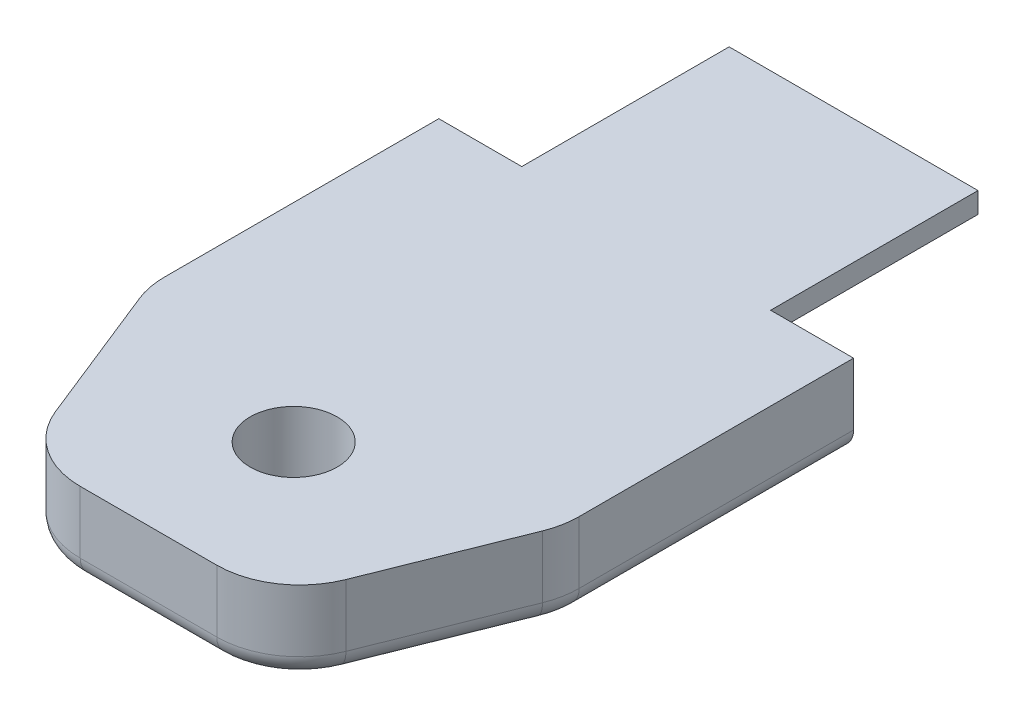
from build123d import *

# Parameters (mm, degrees)
BOSS_EXTRU_1_DEPTH      = 10
ESQUISSE2_W             = 20
ESQUISSE2_H             = 4
BOSS_EXTRU_2_DEPTH      = 24
ESQUISSE3_R             = 2.1
ENL_V_MAT_EXTRU_1_DEPTH = 5
CHANFREIN1_SIZE         = 10
CHANFREIN1_SIZE2        = 4
CHANFREIN1_PART_2_SIZE  = 10
CHANFREIN1_PART_2_SIZE2 = 4
CONG_1_R                = 4
CONG_2_R                = 1


with BuildPart() as part:
    # Esquisse1 → Boss.-Extru.1 (new body)
    with BuildSketch(Plane.XY):
        Polygon((-3, 0), (3, 0), (6, 3), (6, 4), (-6, 4), (-6, 3), align=None)
    extrude(amount=BOSS_EXTRU_1_DEPTH)

    # Esquisse2 → Boss.-Extru.2 (add)
    with BuildSketch(Plane.XY.offset(10)):
        with Locations((0, 2)):
            Rectangle(ESQUISSE2_W, ESQUISSE2_H)
    extrude(amount=BOSS_EXTRU_2_DEPTH)

    # Esquisse3 → Enlèv. mat.-Extru.1 (cut, through all)
    with BuildSketch(Plane.XZ):
        with Locations((0, 27)):
            Circle(ESQUISSE3_R)
    extrude(amount=-ENL_V_MAT_EXTRU_1_DEPTH, mode=Mode.SUBTRACT)

    # Chanfrein1
    chanfrein1_edges = [part.edges().sort_by_distance(p)[0] for p in [
        (-10, 2, 34),
    ]]
    chanfrein1_side = [part.faces().sort_by_distance(p)[0] for p in [
        (-10, 2, 22),
    ]]
    chamfer(chanfrein1_edges, length=CHANFREIN1_SIZE, length2=CHANFREIN1_SIZE2, reference=chanfrein1_side[0])

    # Chanfrein1 part 2
    chanfrein1_part_2_edges = [part.edges().sort_by_distance(p)[0] for p in [
        (10, 2, 34),
    ]]
    chanfrein1_part_2_side = [part.faces().sort_by_distance(p)[0] for p in [
        (10, 2, 22),
    ]]
    chamfer(chanfrein1_part_2_edges, length=CHANFREIN1_PART_2_SIZE, length2=CHANFREIN1_PART_2_SIZE2, reference=chanfrein1_part_2_side[0])

    # Congé1
    cong_1_edges = [part.edges().sort_by_distance(p)[0] for p in [
        (-6, 2, 34),
        (6, 2, 34),
        (10, 2, 24),
        (-10, 2, 24),
    ]]
    fillet(cong_1_edges, radius=CONG_1_R)

    # Congé2
    cong_2_edges = [part.edges().sort_by_distance(p)[0] for p in [
        (10, 0, 16.614835193),
        (9.927825547, 0, 23.98610047),
        (8.359840841, 0, 28.100397898),
        (5.534383392, 0, 33.312268922),
        (0, 0, 34),
        (-5.534383392, 0, 33.312268922),
        (-8.359840841, 0, 28.100397898),
        (-9.927825547, 0, 23.98610047),
        (-10, 0, 16.614835193),
    ]]
    fillet(cong_2_edges, radius=CONG_2_R)


solid = part.part
